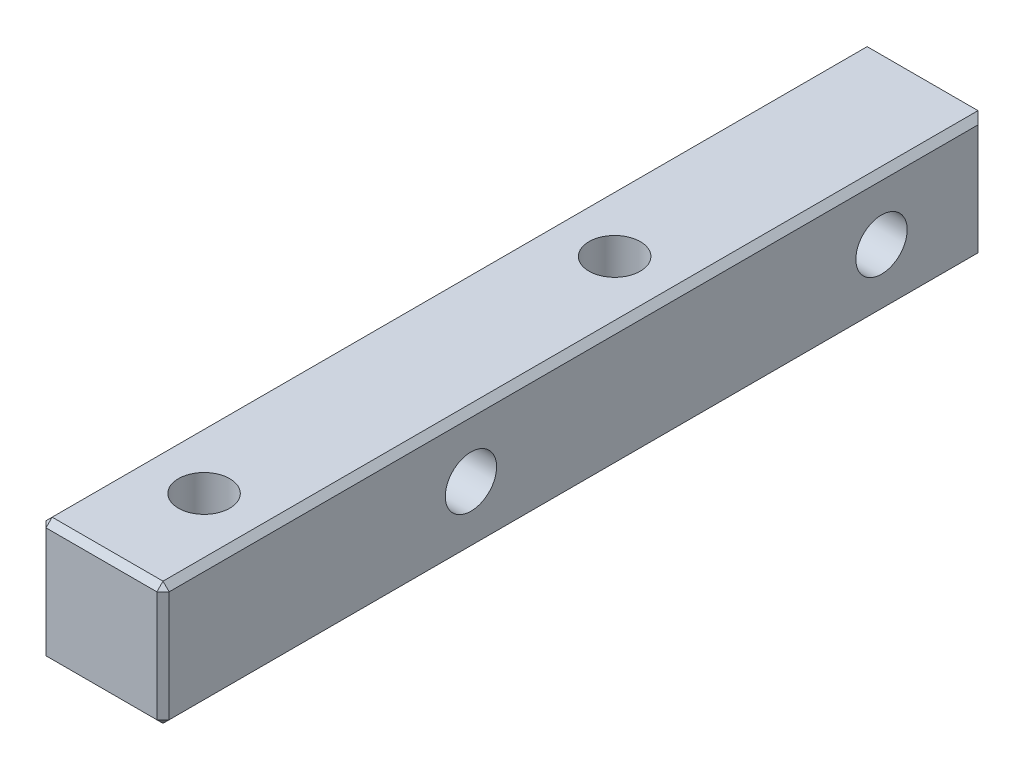
from build123d import *

# Parameters (mm, degrees)
SKETCH_1_W          = 6
SKETCH_1_H          = 6
EXTRUDE_1_DEPTH     = 20
HOLE_WIZARD_1_D     = 2.5
HOLE_WIZARD_1_DEPTH = 6
HOLE_WIZARD_2_D     = 2.5
HOLE_WIZARD_2_DEPTH = 6
CHAMFER_1_SIZE      = 0.3


with BuildPart() as part:
    # 草图1 → 凸台-拉伸1 (new body, symmetric)
    with BuildSketch(Plane.XY):
        Rectangle(SKETCH_1_W, SKETCH_1_H)
    extrude(amount=EXTRUDE_1_DEPTH, both=True)

    # Hole Wizard 1
    with Locations(Plane.ZY.offset(3)):
        with Locations((-15, 0), (5, 0)):
            Hole(HOLE_WIZARD_1_D / 2, depth=HOLE_WIZARD_1_DEPTH)

    # Hole Wizard 2
    with Locations(Plane(origin=(0, 3, 0), x_dir=(1, 0, 0), z_dir=(0, 1, 0))):
        with Locations((0, 5), (0, -15)):
            Hole(HOLE_WIZARD_2_D / 2, depth=HOLE_WIZARD_2_DEPTH)

    # 倒角1
    chamfer_1_edges = [part.edges().sort_by_distance(p)[0] for p in [
        (-3, 0, 20),
        (0, -3, 20),
        (3, 0, 20),
        (0, -3, -20),
        (-3, 0, -20),
        (3, 0, -20),
        (3, -3, 0),
        (-3, -3, 0),
        (-3, 3, 0),
        (3, 3, 0),
        (0, 3, 20),
    ]]
    chamfer(chamfer_1_edges, length=CHAMFER_1_SIZE)


solid = part.part
